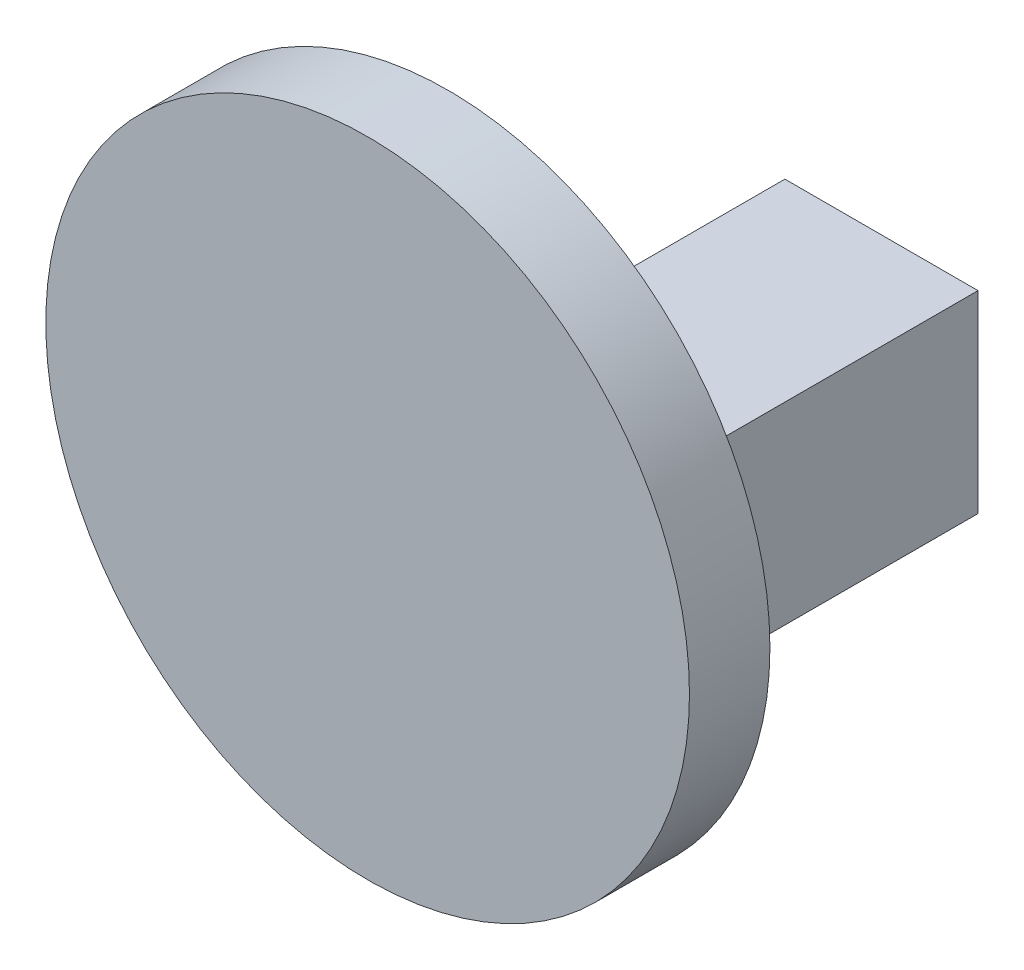
from build123d import *

# Parameters (mm, degrees)
BOSS_EXTRUDE1_DEPTH      = 5
BOSS_EXTRUDE1_DEPTH_BACK = 7
SKETCH3_R                = 20
BOSS_EXTRUDE2_DEPTH      = 5
FILLET1_R                = 0.5
SKETCH6_R                = 3.75
CUT_EXTRUDE1_DEPTH       = 15


with BuildPart() as part:
    # Sketch1 → Boss-Extrude1 (new body, two sides)
    with BuildSketch(Plane.ZY.offset(-66.898173267)) as boss_extrude1_sk:
        Polygon((275.981331654, 12.55), (275.981331654, 0.55), (254.516262845, 0.55), (252.302759373, 0.55), (252.302759373, 12.55), (254.516262845, 12.55), align=None)
    extrude(amount=BOSS_EXTRUDE1_DEPTH)
    extrude(boss_extrude1_sk.sketch, amount=-BOSS_EXTRUDE1_DEPTH_BACK)

    # Sketch3 → Boss-Extrude2 (add)
    with BuildSketch(Plane.XY.offset(275.981331654)):
        with Locations((64.647096069, 10.55)):
            Circle(SKETCH3_R)
    extrude(amount=BOSS_EXTRUDE2_DEPTH)

    # Fillet1
    fillet1_edges = [part.edges().sort_by_distance(p)[0] for p in [
        (67.898173267, 12.55, 275.981331654),
        (67.898173267, 0.55, 275.981331654),
        (73.898173267, 6.55, 275.981331654),
        (61.898173267, 6.55, 275.981331654),
    ]]
    fillet(fillet1_edges, radius=FILLET1_R)

    # Sketch6 → Cut-Extrude1 (cut)
    with BuildSketch(Plane(origin=(0, 0, 252.302759373), x_dir=(-1, 0, 0), z_dir=(0, 0, -1))):
        with Locations((-67.969208633, 7.013446821)):
            Circle(SKETCH6_R)
    extrude(amount=-CUT_EXTRUDE1_DEPTH, mode=Mode.SUBTRACT)


solid = part.part
